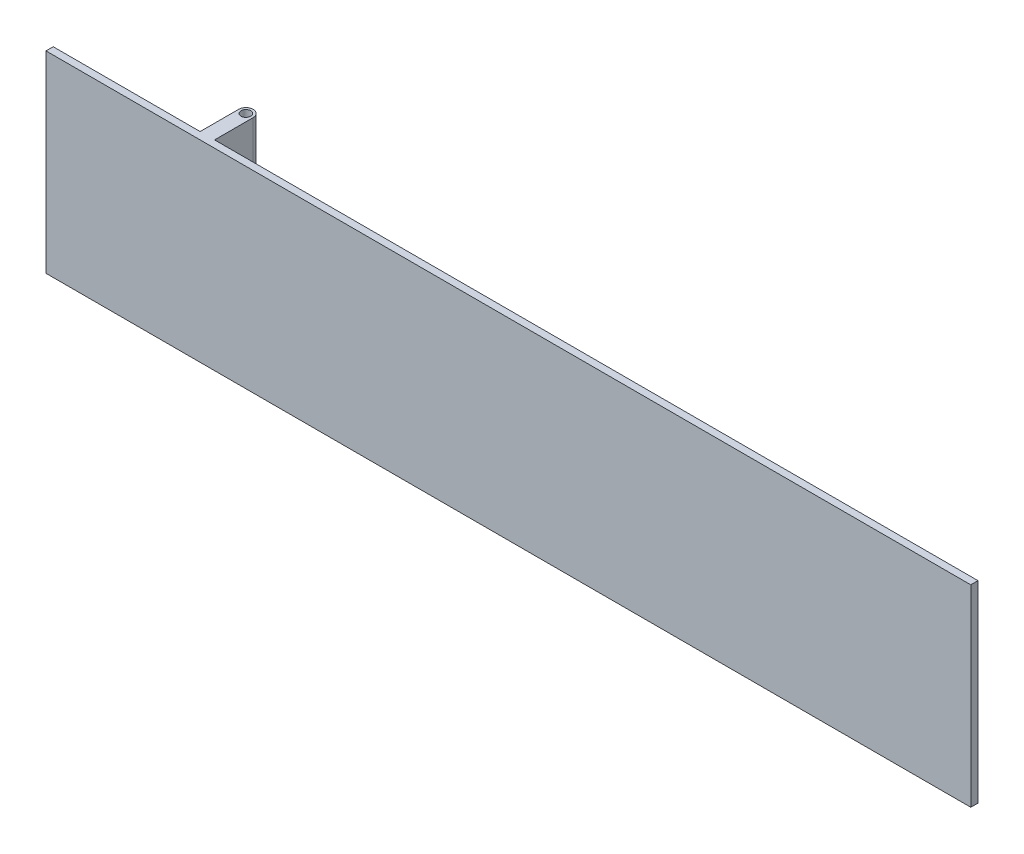
from build123d import *

# Parameters (mm, degrees)
SKETCH1_W           = 609.6
SKETCH1_H           = 127
BOSS_EXTRUDE2_DEPTH = 4.7625
SKETCH3_R           = 3.175
BOSS_EXTRUDE3_DEPTH = 63.5
SKETCH4_W           = 30.1625
SKETCH4_H           = 50.8
CUT_EXTRUDE1_DEPTH  = 107.3625


with BuildPart() as part:
    # Sketch1 → Boss-Extrude2 (new body)
    with BuildSketch(Plane.XY):
        Rectangle(SKETCH1_W, SKETCH1_H)
    extrude(amount=BOSS_EXTRUDE2_DEPTH)

    # Sketch3 → Boss-Extrude3 (add, symmetric)
    with BuildSketch(Plane(origin=(0, 0, 0), x_dir=(1, 0, 0), z_dir=(0, 1, 0))):
        with BuildLine():
            Line((-207.9625, 0), (-207.9625, 25.4))
            ThreePointArc((-207.9625, 25.4), (-203.2, 30.1625), (-198.4375, 25.4))
            Line((-198.4375, 25.4), (-198.4375, 0))
            Line((-198.4375, 0), (-207.9625, 0))
        make_face()
        with Locations((-203.2, 25.4)):
            Circle(SKETCH3_R, mode=Mode.SUBTRACT)
    extrude(amount=BOSS_EXTRUDE3_DEPTH, both=True)

    # Sketch4 → Cut-Extrude1 (cut, through all)
    with BuildSketch(Plane(origin=(-198.4375, 0, 0), x_dir=(0, 0, -1), z_dir=(1, 0, 0))):
        with Locations((15.08125, 0)):
            Rectangle(SKETCH4_W, SKETCH4_H)
    extrude(amount=-CUT_EXTRUDE1_DEPTH, mode=Mode.SUBTRACT)


solid = part.part
